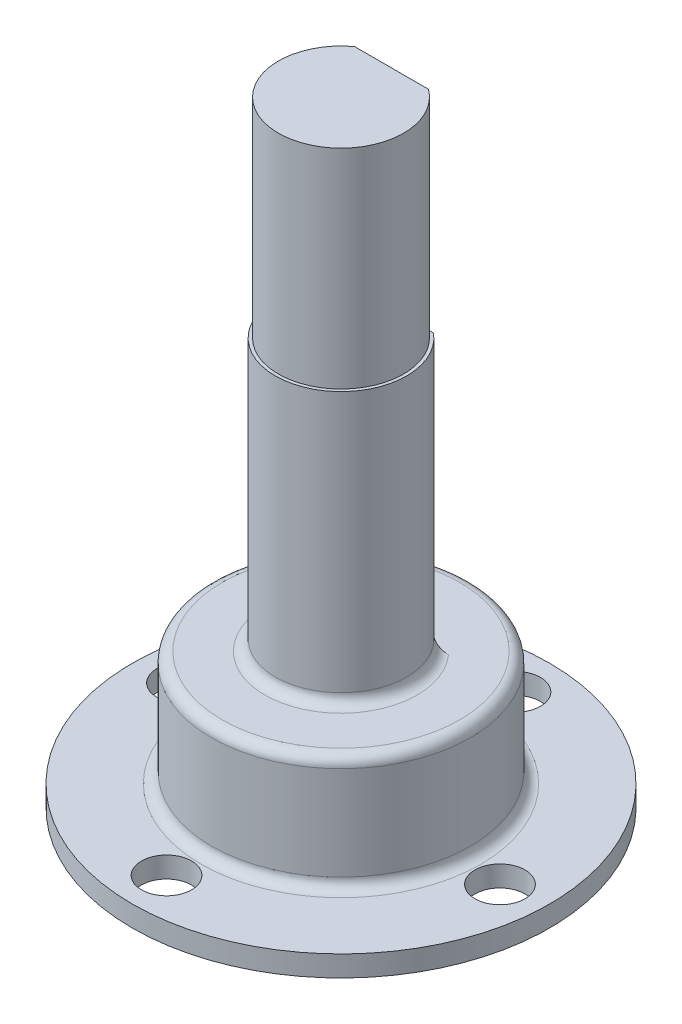
from build123d import *

# Parameters (mm, degrees)
ESQUISSE3_W                  = 6.57785754
ESQUISSE3_H                  = 1.386048805
ENL_V_MAT_EXTRU_1_DEPTH      = 23
D_GAGEMENT_M21_D             = 2.4
D_GAGEMENT_M21_DEPTH         = 1.001
R_P_TITION_CIRCULAIRE1_COUNT = 4
FILLET1_R                    = 0.5


with BuildPart() as part:
    # Esquisse2 → Révolution2 (revolve)
    with BuildSketch(Plane.XY):
        Polygon((0, 29.5), (3, 29.5), (3, 19.5), (3.15, 19.5), (3.15, 6.5), (6.2, 6.5), (6.2, 3), (6.2, 1), (10, 1), (10, 0), (4.5, 0), (4.5, 3), (0, 3), align=None)
    revolve(axis=Axis((0, 3, 0), (0, 1, 0)))

    # Esquisse3 → Enlèv. mat.-Extru.1 (cut)
    with BuildSketch(Plane(origin=(0, 29.5, 0), x_dir=(1, 0, 0), z_dir=(0, 1, 0))):
        with Locations((-0.352413472, 3.114928535)):
            Rectangle(ESQUISSE3_W, ESQUISSE3_H)
    extrude(amount=-ENL_V_MAT_EXTRU_1_DEPTH, mode=Mode.SUBTRACT)

    # Dégagement M21
    with Locations(Plane(origin=(0, 1, 0), x_dir=(1, 0, 0), z_dir=(0, 1, 0))):
        with Locations((0.371303159, 7.991378727)):
            d_gagement_m21 = Hole(D_GAGEMENT_M21_D / 2, depth=D_GAGEMENT_M21_DEPTH)

    # Répétition circulaire1: Dégagement M21 ×4 about axis
    r_p_tition_circulaire1_axis = Axis((0, 0, 0), (0, 1, 0))
    for i in range(1, R_P_TITION_CIRCULAIRE1_COUNT):
        add(d_gagement_m21.rotate(r_p_tition_circulaire1_axis, i * 360 / R_P_TITION_CIRCULAIRE1_COUNT), mode=Mode.SUBTRACT)

    # Fillet1
    fillet1_edges = [part.edges().sort_by_distance(p)[0] for p in [
        (-6.2, 1, 0),
        (-6.2, 6.5, 0),
        (0, 6.5, 3.15),
    ]]
    fillet(fillet1_edges, radius=FILLET1_R)


solid = part.part
